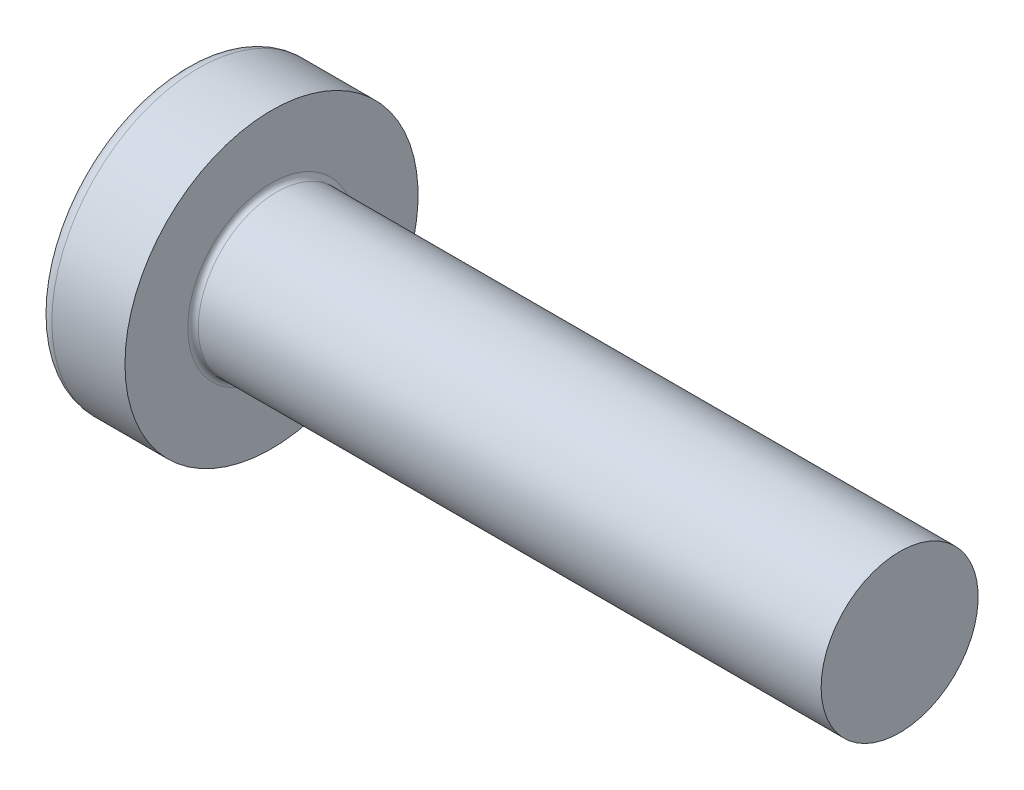
from build123d import *

# Parameters (mm, degrees)
FILLET1_R    = 0.1
SKETCH3_W    = 0.74
SKETCH3_H    = 2.8
SKETCH4_W    = 0.74
SKETCH4_H    = 1.054964432
RECPAT_COUNT = 2
RECPAT_ANGLE = 90


with BuildPart() as part:
    # BodySke → Base-Revolve (revolve)
    with BuildSketch(Plane.XY):
        with BuildLine():
            Line((2.4, 1.5), (2.4, 2.8))
            Line((2.4, 2.8), (1.003501533, 2.8))
            ThreePointArc((1.003501533, 2.8), (0.873295971, 2.76653015), (0.775371599, 2.674418605))
            ThreePointArc((0.775371599, 2.674418605), (0.197753546, 1.392274756), (0, 0))
            Line((0, 0), (14.4, 0))
            Line((14.4, 0), (14.4, 1.5))
            Line((14.4, 1.5), (2.4, 1.5))
        make_face()
    revolve(axis=Axis((-25.4, 0, 0), (1, 0, 0)))

    # Fillet1
    fillet1_edges = [part.edges().sort_by_distance(p)[0] for p in [
        (2.4, -1.5, 0),
    ]]
    fillet(fillet1_edges, radius=FILLET1_R)

    # Sketch3 → Recess section 0
    with BuildSketch(Plane(origin=(0, 0, 0), x_dir=(0, 0, -1), z_dir=(1, 0, 0))):
        Rectangle(SKETCH3_W, SKETCH3_H)
    # Sketch4 → Recess section 1
    with BuildSketch(Plane(origin=(1.75, 0, 0), x_dir=(0, 0, -1), z_dir=(1, 0, 0))):
        Rectangle(SKETCH4_W, SKETCH4_H)
    recess = loft(mode=Mode.SUBTRACT)

    # RecPat: Recess ×2 about axis
    recpat_axis = Axis((0, 0, 0), (1, 0, 0))
    for i in range(1, RECPAT_COUNT):
        add(recess.rotate(recpat_axis, i * RECPAT_ANGLE / (RECPAT_COUNT - 1)), mode=Mode.SUBTRACT)

    # RecCorSke → RecessCore (revolve, cut)
    with BuildSketch(Plane.XY):
        Polygon((0, 0), (0, 0.678371921), (1.75, 0.556), (1.930655351, 0), align=None)
    revolve(axis=Axis((-3.175, 0, 0), (1, 0, 0)), mode=Mode.SUBTRACT)


solid = part.part
